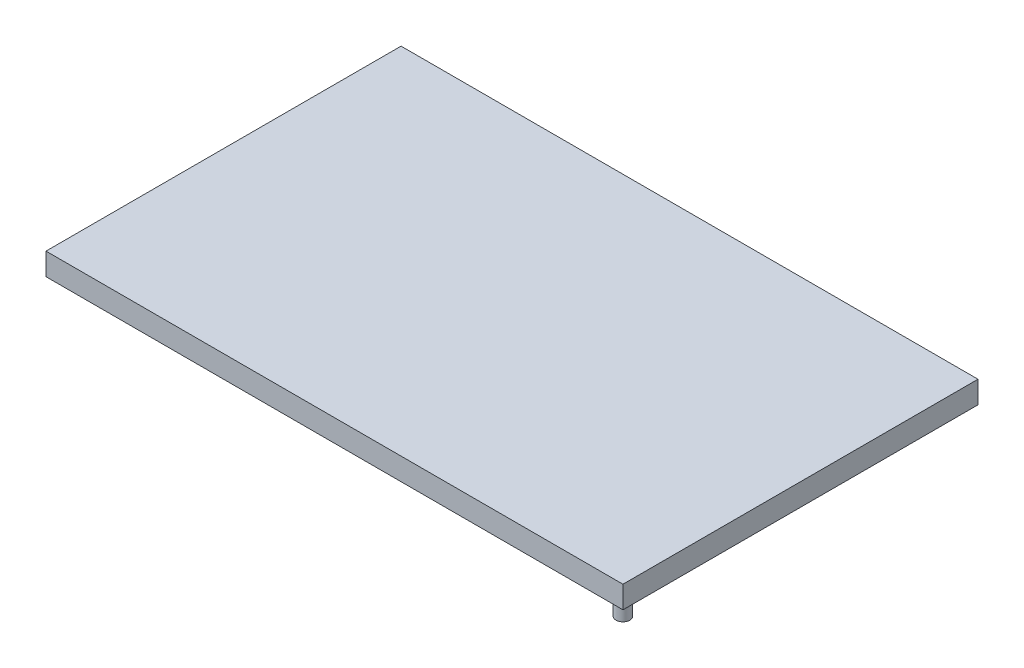
from build123d import *

# Parameters (mm, degrees)
CROQUIS1_W              = 208
CROQUIS1_H              = 128
SALIENTE_EXTRUIR1_DEPTH = 8
CROQUIS1_4_W            = 200
CROQUIS1_4_H            = 120
CORTAR_EXTRUIR1_DEPTH   = 4
CROQUIS2_R              = 2.5
SALIENTE_EXTRUIR2_DEPTH = 20


with BuildPart() as part:
    # Croquis1 → Saliente-Extruir1 (new body)
    with BuildSketch(Plane(origin=(0, 0, 0), x_dir=(1, 0, 0), z_dir=(0, 1, 0))):
        Rectangle(CROQUIS1_W, CROQUIS1_H)
    extrude(amount=SALIENTE_EXTRUIR1_DEPTH)

    # Croquis1_4 → Cortar-Extruir1 (cut)
    with BuildSketch(Plane(origin=(0, 0, 0), x_dir=(1, 0, 0), z_dir=(0, 1, 0))):
        Rectangle(CROQUIS1_4_W, CROQUIS1_4_H)
    extrude(amount=CORTAR_EXTRUIR1_DEPTH, mode=Mode.SUBTRACT)

    # Croquis2 → Saliente-Extruir2 (add)
    with BuildSketch(Plane.XZ.offset(-4)):
        with Locations((-90, -50)):
            Circle(CROQUIS2_R)
        with Locations((90, 50)):
            Circle(CROQUIS2_R)
    extrude(amount=SALIENTE_EXTRUIR2_DEPTH)


solid = part.part
